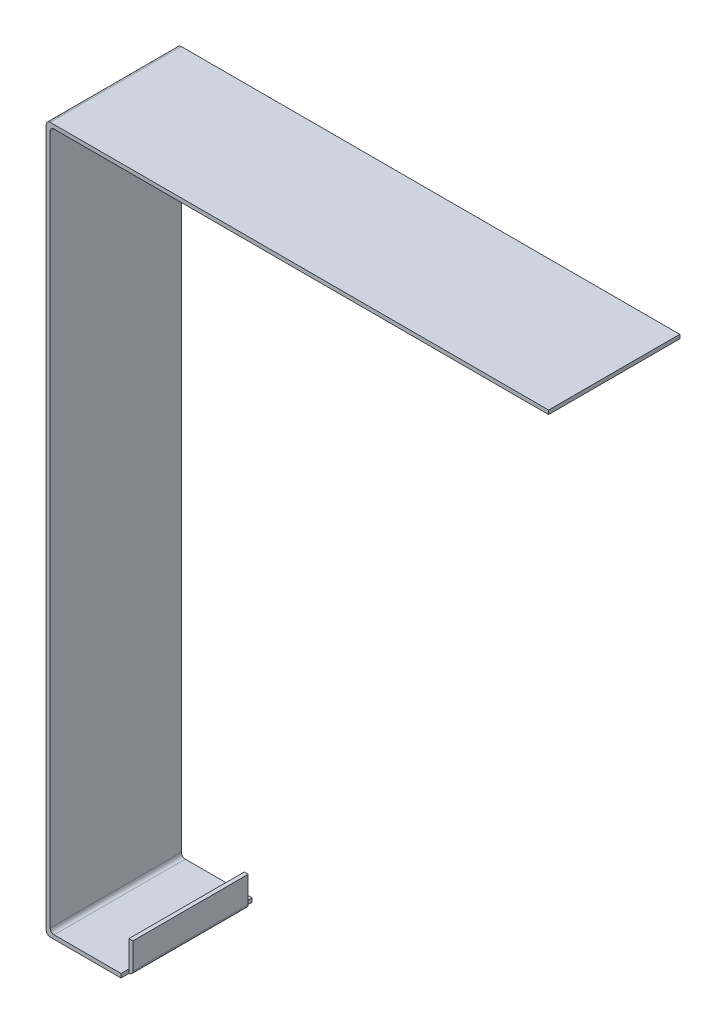
from build123d import *

# Parameters (mm, degrees)
EXTRUDE_1_DEPTH     = 50
SKETCH_3_W          = 3
SKETCH_3_H          = 11.5
CUT_EXTRUDE_1_DEPTH = 1.5
FILLET_1_R          = 1.5


with BuildPart() as part:
    # 草图1 → 凸台-拉伸1 (new body)
    with BuildSketch(Plane.XY):
        with BuildLine():
            Line((-40.582688737, 29.861069553), (147.917311263, 29.861069553))
            Line((147.917311263, 29.861069553), (147.917311263, 31.361069553))
            Line((147.917311263, 31.361069553), (-42.082688737, 31.361069553))
            ThreePointArc((-42.082688737, 31.361069553), (-43.143348909, 30.921729725), (-43.582688737, 29.861069553))
            Line((-43.582688737, 29.861069553), (-43.582688737, -236.138930447))
            ThreePointArc((-43.582688737, -236.138930447), (-43.143348909, -237.199590619), (-42.082688737, -237.638930447))
            Line((-42.082688737, -237.638930447), (-15.082688737, -237.638930447))
            Line((-15.082688737, -237.638930447), (-13.582688737, -237.638930447))
            Line((-13.582688737, -237.638930447), (-13.582688737, -236.138930447))
            Line((-13.582688737, -236.138930447), (-13.582688737, -226.138930447))
            Line((-13.582688737, -226.138930447), (-15.082688737, -226.138930447))
            Line((-15.082688737, -226.138930447), (-15.082688737, -234.638930447))
            Line((-15.082688737, -234.638930447), (-15.082688737, -236.138930447))
            Line((-15.082688737, -236.138930447), (-16.582688737, -236.138930447))
            Line((-16.582688737, -236.138930447), (-40.582688737, -236.138930447))
            ThreePointArc((-40.582688737, -236.138930447), (-41.643348909, -235.699590619), (-42.082688737, -234.638930447))
            Line((-42.082688737, -234.638930447), (-42.082688737, -226.138930447))
            Line((-42.082688737, -226.138930447), (-42.082688737, -50.138930447))
            Line((-42.082688737, -50.138930447), (-42.082688737, 28.361069553))
            ThreePointArc((-42.082688737, 28.361069553), (-41.643348909, 29.421729725), (-40.582688737, 29.861069553))
        make_face()
    extrude(amount=EXTRUDE_1_DEPTH)

    # 草图3 → 切除-拉伸1 (cut)
    with BuildSketch(Plane(origin=(-13.582688737, 0, 0), x_dir=(0, 0, -1), z_dir=(1, 0, 0))):
        with Locations((-48.5, -231.888930447)):
            Rectangle(SKETCH_3_W, SKETCH_3_H)
        with Locations((-1.5, -231.888930447)):
            Rectangle(SKETCH_3_W, SKETCH_3_H)
    extrude(amount=-CUT_EXTRUDE_1_DEPTH, mode=Mode.SUBTRACT)

    # 圆角1
    fillet_1_edges = [part.edges().sort_by_distance(p)[0] for p in [
        (-13.582688737, -237.638930447, 25),
    ]]
    fillet(fillet_1_edges, radius=FILLET_1_R)


solid = part.part
